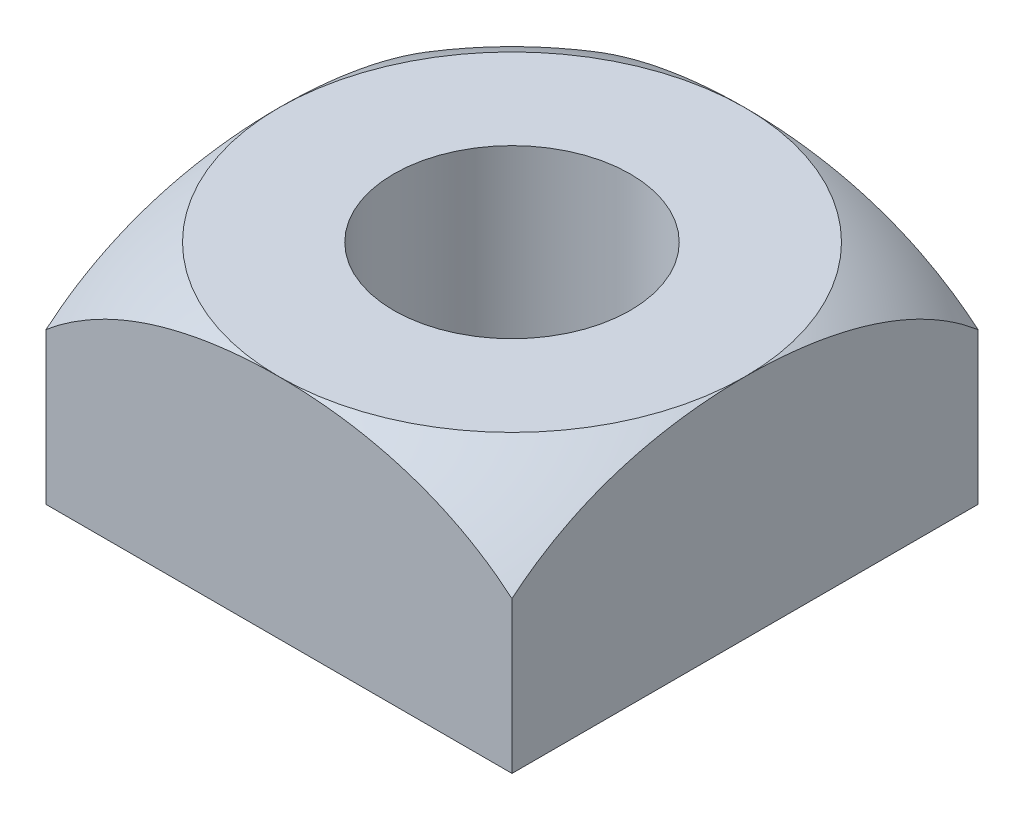
from build123d import *

# Parameters (mm, degrees)
SKETCH1_W               = 9.85
SKETCH1_H               = 9.85
BOSS_EXTRUDE1_DEPTH     = 4.8
SKETCH2_R               = 2.5
CUT_EXTRUDE2_DEPTH      = 5.8
CUT_EXTRUDE2_DEPTH_BACK = 1


with BuildPart() as part:
    # Sketch1 → Boss-Extrude1 (new body)
    with BuildSketch(Plane(origin=(0, 0, 0), x_dir=(1, 0, 0), z_dir=(0, 1, 0))):
        Rectangle(SKETCH1_W, SKETCH1_H)
    extrude(amount=BOSS_EXTRUDE1_DEPTH)

    # Sketch2 → Cut-Extrude2 (cut, two sides)
    with BuildSketch(Plane(origin=(0, 0, 0), x_dir=(1, 0, 0), z_dir=(0, 1, 0))) as cut_extrude2_sk:
        Circle(SKETCH2_R)
    extrude(amount=CUT_EXTRUDE2_DEPTH, mode=Mode.SUBTRACT)
    extrude(cut_extrude2_sk.sketch, amount=-CUT_EXTRUDE2_DEPTH_BACK, mode=Mode.SUBTRACT)

    # Sketch4 → Cut-Revolve3 (revolve, cut)
    with BuildSketch(Plane.XY):
        with BuildLine():
            Line((4.377231808, 5.035384903), (7.488107991, 5.035384903))
            Line((7.488107991, 5.035384903), (7.488107991, 2.471192453))
            ThreePointArc((7.488107991, 2.471192453), (6.147264146, 4.013634243), (4.377231808, 5.035384903))
        make_face()
    revolve(axis=Axis((0, 0, 0), (0, 1, 0)), mode=Mode.SUBTRACT)


solid = part.part
